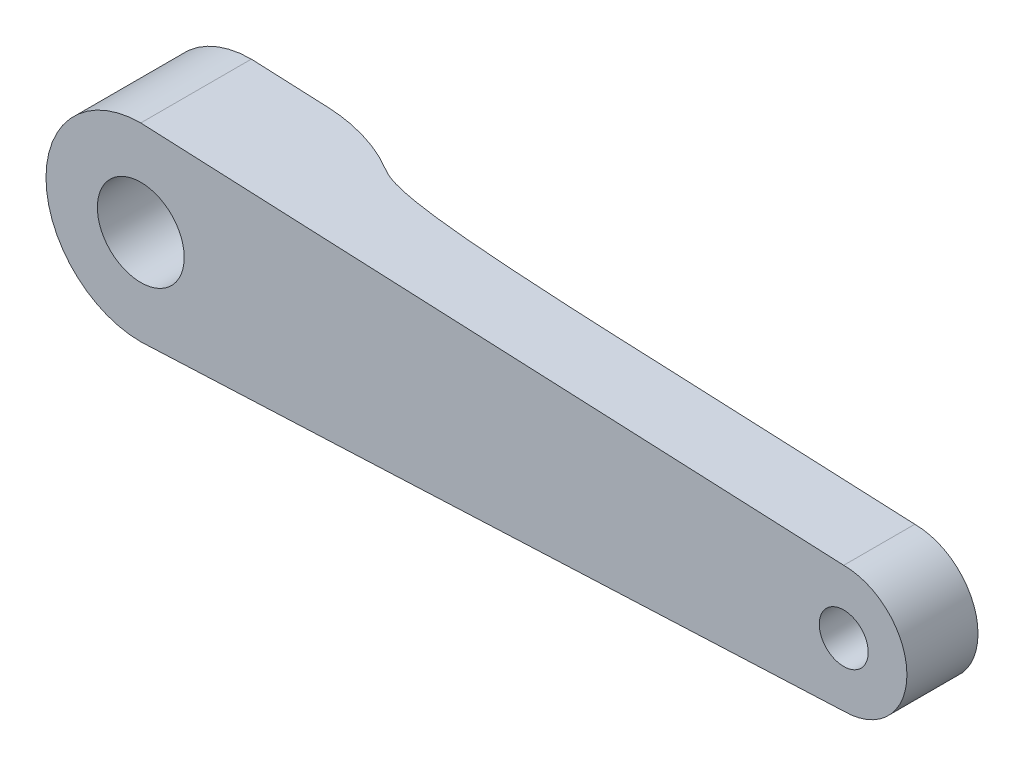
from build123d import *

# Parameters (mm, degrees)
SKETCH1_R               = 1.55
BOSS_EXTRUDE1_DEPTH     = 7
SKETCH2_R               = 2.75
CUT_EXTRUDE1_DEPTH      = 5
SKETCH3_R               = 1.75
CUT_EXTRUDE2_DEPTH      = 5
CUT_EXTRUDE4_DEPTH      = 7
CUT_EXTRUDE4_DEPTH_BACK = 7
FILLET1_R               = 10


with BuildPart() as part:
    # Sketch1 → Boss-Extrude1 (new body)
    with BuildSketch(Plane.XY):
        with BuildLine():
            ThreePointArc((0, 6), (-6, 0), (0, -6))
            Line((0, -6), (44.5, -4))
            ThreePointArc((44.5, -4), (48.5, 0), (44.5, 4))
            Line((44.5, 4), (0, 6))
        make_face()
        with Locations((44.5, 0)):
            Circle(SKETCH1_R, mode=Mode.SUBTRACT)
    extrude(amount=BOSS_EXTRUDE1_DEPTH)

    # Sketch2 → Cut-Extrude1 (cut)
    with BuildSketch(Plane.XY.offset(7)):
        Circle(SKETCH2_R)
    extrude(amount=-CUT_EXTRUDE1_DEPTH, mode=Mode.SUBTRACT)

    # Sketch3 → Cut-Extrude2 (cut)
    with BuildSketch(Plane(origin=(0, 0, 0), x_dir=(-1, 0, 0), z_dir=(0, 0, -1))):
        Circle(SKETCH3_R)
    extrude(amount=-CUT_EXTRUDE2_DEPTH, mode=Mode.SUBTRACT)

    # Sketch5 → Cut-Extrude4 (cut, two sides)
    with BuildSketch(Plane(origin=(0, 0, 0), x_dir=(1, 0, 0), z_dir=(0, 1, 0))) as cut_extrude4_sk:
        with BuildLine():
            Line((48.5, 0), (48.5, -2.5))
            Line((48.5, -2.5), (28.5, -2.5))
            add(Edge.make_bspline(
                [(9, 0), (9.734542775, -1.732075598), (8.772191405, -2.578671179), (28.5, -2.5)],
                knots=[0, 0, 0, 0, 1, 1, 1, 1], degree=3))
            Line((9, 0), (48.5, 0))
        make_face()
    extrude(amount=CUT_EXTRUDE4_DEPTH, mode=Mode.SUBTRACT)
    extrude(cut_extrude4_sk.sketch, amount=-CUT_EXTRUDE4_DEPTH_BACK, mode=Mode.SUBTRACT)

    # Fillet1
    fillet1_edges = [part.edges().sort_by_distance(p)[0] for p in [
        (9, 2.797752809, 0),
    ]]
    fillet(fillet1_edges, radius=FILLET1_R)


solid = part.part
